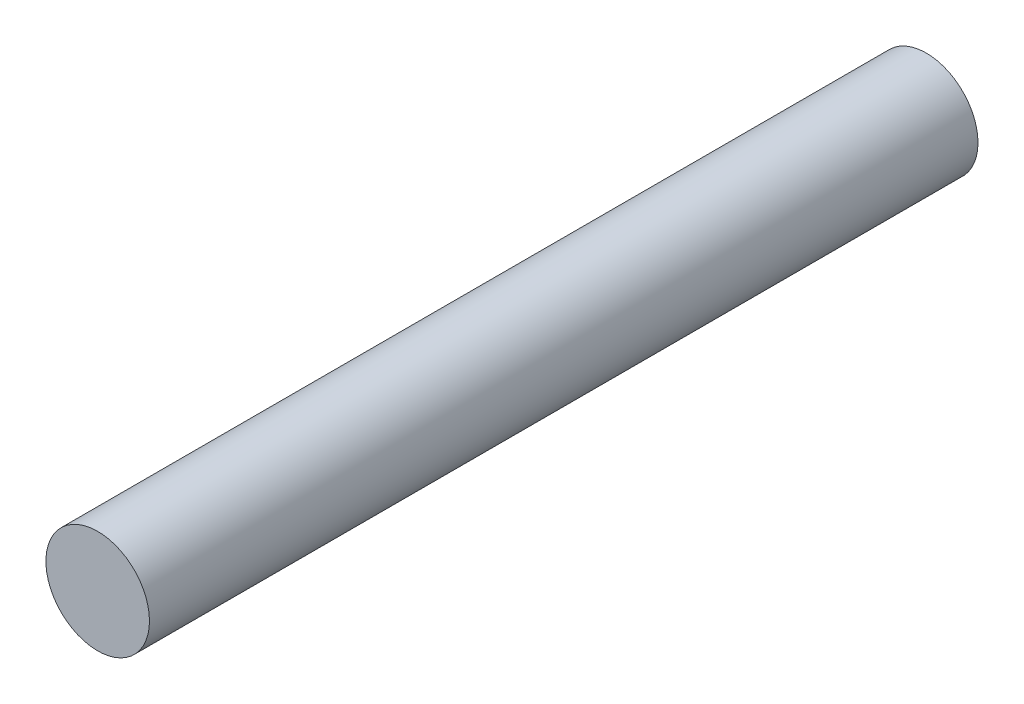
from build123d import *

# Parameters (mm, degrees)
SKETCH1_R           = 1
BOSS_EXTRUDE1_DEPTH = 16


with BuildPart() as part:
    # Sketch1 → Boss-Extrude1 (new body)
    with BuildSketch(Plane.XY):
        Circle(SKETCH1_R)
    extrude(amount=BOSS_EXTRUDE1_DEPTH)


solid = part.part
